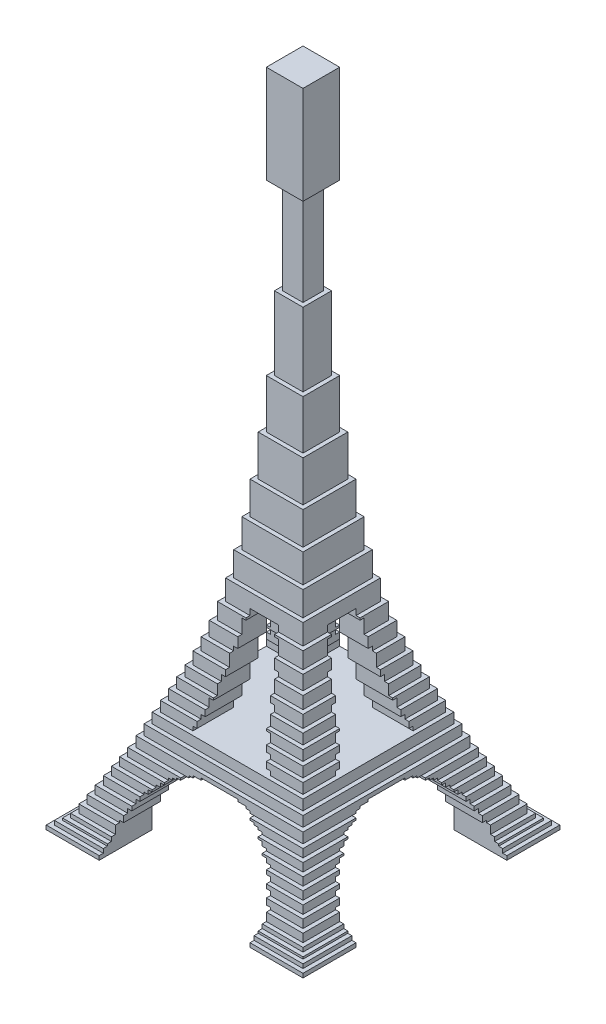
from build123d import *

# Parameters (mm, degrees)
SKIZZE2_W                            = 63
SKIZZE2_H                            = 162
AUFSATZ_LINEAR_AUSTRAGEN1_DEPTH      = 31.5
AUFSATZ_LINEAR_AUSTRAGEN1_DEPTH_BACK = 31.5
SCHNITT_LINEAR_AUSTRAGEN2_DEPTH      = 32.5
SCHNITT_LINEAR_AUSTRAGEN3_DEPTH      = 32.5
SCHNITT_LINEAR_AUSTRAGEN4_DEPTH      = 32.5
KREISMUSTER1_COUNT                   = 4
KREISMUSTER1_COPY_1_DEPTH            = 32.5
KREISMUSTER1_COPY_2_DEPTH            = 32.5
KREISMUSTER1_COPY_3_DEPTH            = 32.5
KREISMUSTER1_COPY_4_DEPTH            = 32.5
KREISMUSTER1_COPY_5_DEPTH            = 32.5
KREISMUSTER1_COPY_6_DEPTH            = 32.5
KREISMUSTER1_COPY_7_DEPTH            = 32.5
KREISMUSTER1_COPY_8_DEPTH            = 32.5
KREISMUSTER1_COPY_9_DEPTH            = 32.5
KREISMUSTER1_COPY_10_DEPTH           = 32.5
KREISMUSTER1_COPY_11_DEPTH           = 32.5
KREISMUSTER1_COPY_12_DEPTH           = 32.5


with BuildPart() as part:
    # Skizze2 → Aufsatz-Linear austragen1 (new body, two sides)
    with BuildSketch(Plane.XY) as aufsatz_linear_austragen1_sk:
        with Locations((0, 81)):
            Rectangle(SKIZZE2_W, SKIZZE2_H)
    extrude(amount=AUFSATZ_LINEAR_AUSTRAGEN1_DEPTH)
    extrude(aufsatz_linear_austragen1_sk.sketch, amount=-AUFSATZ_LINEAR_AUSTRAGEN1_DEPTH_BACK)

    # Skizze4 → Schnitt-Linear austragen2 (cut, symmetric)
    with BuildSketch(Plane.XY):
        Polygon((-18.5, 0), (-18.5, 6), (-17.5, 6), (-17.5, 8.5), (-16.5, 8.5), (-16.5, 10.5), (-15.5, 10.5), (-15.5, 12), (-14.5, 12), (-14.5, 13), (-13.5, 13), (-13.5, 14), (-12.5, 14), (-12.5, 15), (-11.5, 15), (-11.5, 16), (-10.5, 16), (-10.5, 16.5), (-9.5, 16.5), (-9.5, 17), (-8.5, 17), (-8.5, 17.5), (-7.5, 17.5), (-7.5, 18), (-6.5, 18), (-6.5, 18.5), (-4.5, 18.5), (-4.5, 19), (0, 19), (0, 0), align=None)
    schnitt_linear_austragen2 = extrude(amount=SCHNITT_LINEAR_AUSTRAGEN2_DEPTH, both=True, mode=Mode.SUBTRACT)

    # Skizze5 → Schnitt-Linear austragen3 (cut, symmetric)
    with BuildSketch(Plane.XY):
        Polygon((0, 50), (-3.5, 50), (-3.5, 48), (-4.5, 48), (-4.5, 42), (-5.5, 42), (-5.5, 36.5), (-6.5, 36.5), (-6.5, 32), (-7.5, 32), (-7.5, 28.5), (-8.5, 28.5), (-8.5, 26), (-9.5, 26), (-9.5, 25), (0, 25), align=None)
    schnitt_linear_austragen3 = extrude(amount=SCHNITT_LINEAR_AUSTRAGEN3_DEPTH, both=True, mode=Mode.SUBTRACT)

    # Skizze6 → Schnitt-Linear austragen4 (cut, symmetric)
    with BuildSketch(Plane.XY):
        Polygon((-4.5, 162), (-4.5, 138), (-2.5, 138), (-2.5, 114.5), (-3.5, 114.5), (-3.5, 96.5), (-4.5, 96.5), (-4.5, 84.5), (-5.5, 84.5), (-5.5, 74.5), (-6.5, 74.5), (-6.5, 66.5), (-7.5, 66.5), (-7.5, 59.5), (-8.5, 59.5), (-8.5, 53.5), (-9.5, 53.5), (-9.5, 48.5), (-10.5, 48.5), (-10.5, 44.5), (-11.5, 44.5), (-11.5, 41), (-12.5, 41), (-12.5, 38), (-13.5, 38), (-13.5, 35), (-14.5, 35), (-14.5, 32.5), (-15.5, 32.5), (-15.5, 30), (-16.5, 30), (-16.5, 27.5), (-17.5, 27.5), (-17.5, 25), (-18.5, 25), (-18.5, 22.5), (-19.5, 22.5), (-19.5, 20), (-20.5, 20), (-20.5, 17.5), (-21.5, 17.5), (-21.5, 15.5), (-22.5, 15.5), (-22.5, 13.5), (-23.5, 13.5), (-23.5, 11.5), (-24.5, 11.5), (-24.5, 9.5), (-25.5, 9.5), (-25.5, 7.5), (-26.5, 7.5), (-26.5, 5.5), (-27.5, 5.5), (-27.5, 3.5), (-28.5, 3.5), (-28.5, 2.5), (-29.5, 2.5), (-29.5, 2), (-30.5, 2), (-30.5, 1), (-31.5, 1), (-31.5, 162), align=None)
    schnitt_linear_austragen4 = extrude(amount=SCHNITT_LINEAR_AUSTRAGEN4_DEPTH, both=True, mode=Mode.SUBTRACT)

    # Spiegeln1: Schnitt-Linear austragen2, Schnitt-Linear austragen3, Schnitt-Linear austragen4 across plane
    add(schnitt_linear_austragen2.mirror(Plane(origin=(0, 0, 0), x_dir=(0, 0, 1), z_dir=(1, 0, 0))), mode=Mode.SUBTRACT)
    add(schnitt_linear_austragen3.mirror(Plane(origin=(0, 0, 0), x_dir=(0, 0, 1), z_dir=(1, 0, 0))), mode=Mode.SUBTRACT)
    add(schnitt_linear_austragen4.mirror(Plane(origin=(0, 0, 0), x_dir=(0, 0, 1), z_dir=(1, 0, 0))), mode=Mode.SUBTRACT)

    # Kreismuster1: Schnitt-Linear austragen2, Schnitt-Linear austragen3 ×4 about axis
    kreismuster1_axis = Axis((0, 0, 0), (0, 1, 0))
    for i in range(1, KREISMUSTER1_COUNT):
        add(schnitt_linear_austragen2.rotate(kreismuster1_axis, i * 360 / KREISMUSTER1_COUNT), mode=Mode.SUBTRACT)
        add(schnitt_linear_austragen3.rotate(kreismuster1_axis, i * 360 / KREISMUSTER1_COUNT), mode=Mode.SUBTRACT)

    # Kreismuster1 copy 1 sketch → Kreismuster1 copy 1 (cut, symmetric)
    with BuildSketch(Plane(origin=(0, 0, 0), x_dir=(0, 0, 1), z_dir=(1, 0, 0))):
        Polygon((-18.5, 0), (-18.5, -6), (-17.5, -6), (-17.5, -8.5), (-16.5, -8.5), (-16.5, -10.5), (-15.5, -10.5), (-15.5, -12), (-14.5, -12), (-14.5, -13), (-13.5, -13), (-13.5, -14), (-12.5, -14), (-12.5, -15), (-11.5, -15), (-11.5, -16), (-10.5, -16), (-10.5, -16.5), (-9.5, -16.5), (-9.5, -17), (-8.5, -17), (-8.5, -17.5), (-7.5, -17.5), (-7.5, -18), (-6.5, -18), (-6.5, -18.5), (-4.5, -18.5), (-4.5, -19), (0, -19), (0, 0), align=None)
    extrude(amount=KREISMUSTER1_COPY_1_DEPTH, both=True, mode=Mode.SUBTRACT)

    # Kreismuster1 copy 2 sketch → Kreismuster1 copy 2 (cut, symmetric)
    with BuildSketch(Plane(origin=(0, 0, 0), x_dir=(1, 0, 0), z_dir=(0, 0, -1))):
        Polygon((-18.5, 0), (-18.5, -6), (-17.5, -6), (-17.5, -8.5), (-16.5, -8.5), (-16.5, -10.5), (-15.5, -10.5), (-15.5, -12), (-14.5, -12), (-14.5, -13), (-13.5, -13), (-13.5, -14), (-12.5, -14), (-12.5, -15), (-11.5, -15), (-11.5, -16), (-10.5, -16), (-10.5, -16.5), (-9.5, -16.5), (-9.5, -17), (-8.5, -17), (-8.5, -17.5), (-7.5, -17.5), (-7.5, -18), (-6.5, -18), (-6.5, -18.5), (-4.5, -18.5), (-4.5, -19), (0, -19), (0, 0), align=None)
    extrude(amount=KREISMUSTER1_COPY_2_DEPTH, both=True, mode=Mode.SUBTRACT)

    # Kreismuster1 copy 3 sketch → Kreismuster1 copy 3 (cut, symmetric)
    with BuildSketch(Plane(origin=(0, 0, 0), x_dir=(0, 0, -1), z_dir=(-1, 0, 0))):
        Polygon((-18.5, 0), (-18.5, -6), (-17.5, -6), (-17.5, -8.5), (-16.5, -8.5), (-16.5, -10.5), (-15.5, -10.5), (-15.5, -12), (-14.5, -12), (-14.5, -13), (-13.5, -13), (-13.5, -14), (-12.5, -14), (-12.5, -15), (-11.5, -15), (-11.5, -16), (-10.5, -16), (-10.5, -16.5), (-9.5, -16.5), (-9.5, -17), (-8.5, -17), (-8.5, -17.5), (-7.5, -17.5), (-7.5, -18), (-6.5, -18), (-6.5, -18.5), (-4.5, -18.5), (-4.5, -19), (0, -19), (0, 0), align=None)
    extrude(amount=KREISMUSTER1_COPY_3_DEPTH, both=True, mode=Mode.SUBTRACT)

    # Kreismuster1 copy 4 sketch → Kreismuster1 copy 4 (cut, symmetric)
    with BuildSketch(Plane(origin=(0, 0, 0), x_dir=(0, 0, 1), z_dir=(1, 0, 0))):
        Polygon((0, -50), (-3.5, -50), (-3.5, -48), (-4.5, -48), (-4.5, -42), (-5.5, -42), (-5.5, -36.5), (-6.5, -36.5), (-6.5, -32), (-7.5, -32), (-7.5, -28.5), (-8.5, -28.5), (-8.5, -26), (-9.5, -26), (-9.5, -25), (0, -25), align=None)
    extrude(amount=KREISMUSTER1_COPY_4_DEPTH, both=True, mode=Mode.SUBTRACT)

    # Kreismuster1 copy 5 sketch → Kreismuster1 copy 5 (cut, symmetric)
    with BuildSketch(Plane(origin=(0, 0, 0), x_dir=(1, 0, 0), z_dir=(0, 0, -1))):
        Polygon((0, -50), (-3.5, -50), (-3.5, -48), (-4.5, -48), (-4.5, -42), (-5.5, -42), (-5.5, -36.5), (-6.5, -36.5), (-6.5, -32), (-7.5, -32), (-7.5, -28.5), (-8.5, -28.5), (-8.5, -26), (-9.5, -26), (-9.5, -25), (0, -25), align=None)
    extrude(amount=KREISMUSTER1_COPY_5_DEPTH, both=True, mode=Mode.SUBTRACT)

    # Kreismuster1 copy 6 sketch → Kreismuster1 copy 6 (cut, symmetric)
    with BuildSketch(Plane(origin=(0, 0, 0), x_dir=(0, 0, -1), z_dir=(-1, 0, 0))):
        Polygon((0, -50), (-3.5, -50), (-3.5, -48), (-4.5, -48), (-4.5, -42), (-5.5, -42), (-5.5, -36.5), (-6.5, -36.5), (-6.5, -32), (-7.5, -32), (-7.5, -28.5), (-8.5, -28.5), (-8.5, -26), (-9.5, -26), (-9.5, -25), (0, -25), align=None)
    extrude(amount=KREISMUSTER1_COPY_6_DEPTH, both=True, mode=Mode.SUBTRACT)

    # Kreismuster1 copy 7 sketch → Kreismuster1 copy 7 (cut, symmetric)
    with BuildSketch(Plane(origin=(0, 0, 0), x_dir=(0, 0, 1), z_dir=(1, 0, 0))):
        Polygon((-4.5, -162), (-4.5, -138), (-2.5, -138), (-2.5, -114.5), (-3.5, -114.5), (-3.5, -96.5), (-4.5, -96.5), (-4.5, -84.5), (-5.5, -84.5), (-5.5, -74.5), (-6.5, -74.5), (-6.5, -66.5), (-7.5, -66.5), (-7.5, -59.5), (-8.5, -59.5), (-8.5, -53.5), (-9.5, -53.5), (-9.5, -48.5), (-10.5, -48.5), (-10.5, -44.5), (-11.5, -44.5), (-11.5, -41), (-12.5, -41), (-12.5, -38), (-13.5, -38), (-13.5, -35), (-14.5, -35), (-14.5, -32.5), (-15.5, -32.5), (-15.5, -30), (-16.5, -30), (-16.5, -27.5), (-17.5, -27.5), (-17.5, -25), (-18.5, -25), (-18.5, -22.5), (-19.5, -22.5), (-19.5, -20), (-20.5, -20), (-20.5, -17.5), (-21.5, -17.5), (-21.5, -15.5), (-22.5, -15.5), (-22.5, -13.5), (-23.5, -13.5), (-23.5, -11.5), (-24.5, -11.5), (-24.5, -9.5), (-25.5, -9.5), (-25.5, -7.5), (-26.5, -7.5), (-26.5, -5.5), (-27.5, -5.5), (-27.5, -3.5), (-28.5, -3.5), (-28.5, -2.5), (-29.5, -2.5), (-29.5, -2), (-30.5, -2), (-30.5, -1), (-31.5, -1), (-31.5, -162), align=None)
    extrude(amount=KREISMUSTER1_COPY_7_DEPTH, both=True, mode=Mode.SUBTRACT)

    # Kreismuster1 copy 8 sketch → Kreismuster1 copy 8 (cut, symmetric)
    with BuildSketch(Plane(origin=(0, 0, 0), x_dir=(1, 0, 0), z_dir=(0, 0, -1))):
        Polygon((-4.5, -162), (-4.5, -138), (-2.5, -138), (-2.5, -114.5), (-3.5, -114.5), (-3.5, -96.5), (-4.5, -96.5), (-4.5, -84.5), (-5.5, -84.5), (-5.5, -74.5), (-6.5, -74.5), (-6.5, -66.5), (-7.5, -66.5), (-7.5, -59.5), (-8.5, -59.5), (-8.5, -53.5), (-9.5, -53.5), (-9.5, -48.5), (-10.5, -48.5), (-10.5, -44.5), (-11.5, -44.5), (-11.5, -41), (-12.5, -41), (-12.5, -38), (-13.5, -38), (-13.5, -35), (-14.5, -35), (-14.5, -32.5), (-15.5, -32.5), (-15.5, -30), (-16.5, -30), (-16.5, -27.5), (-17.5, -27.5), (-17.5, -25), (-18.5, -25), (-18.5, -22.5), (-19.5, -22.5), (-19.5, -20), (-20.5, -20), (-20.5, -17.5), (-21.5, -17.5), (-21.5, -15.5), (-22.5, -15.5), (-22.5, -13.5), (-23.5, -13.5), (-23.5, -11.5), (-24.5, -11.5), (-24.5, -9.5), (-25.5, -9.5), (-25.5, -7.5), (-26.5, -7.5), (-26.5, -5.5), (-27.5, -5.5), (-27.5, -3.5), (-28.5, -3.5), (-28.5, -2.5), (-29.5, -2.5), (-29.5, -2), (-30.5, -2), (-30.5, -1), (-31.5, -1), (-31.5, -162), align=None)
    extrude(amount=KREISMUSTER1_COPY_8_DEPTH, both=True, mode=Mode.SUBTRACT)

    # Kreismuster1 copy 9 sketch → Kreismuster1 copy 9 (cut, symmetric)
    with BuildSketch(Plane(origin=(0, 0, 0), x_dir=(0, 0, -1), z_dir=(-1, 0, 0))):
        Polygon((-4.5, -162), (-4.5, -138), (-2.5, -138), (-2.5, -114.5), (-3.5, -114.5), (-3.5, -96.5), (-4.5, -96.5), (-4.5, -84.5), (-5.5, -84.5), (-5.5, -74.5), (-6.5, -74.5), (-6.5, -66.5), (-7.5, -66.5), (-7.5, -59.5), (-8.5, -59.5), (-8.5, -53.5), (-9.5, -53.5), (-9.5, -48.5), (-10.5, -48.5), (-10.5, -44.5), (-11.5, -44.5), (-11.5, -41), (-12.5, -41), (-12.5, -38), (-13.5, -38), (-13.5, -35), (-14.5, -35), (-14.5, -32.5), (-15.5, -32.5), (-15.5, -30), (-16.5, -30), (-16.5, -27.5), (-17.5, -27.5), (-17.5, -25), (-18.5, -25), (-18.5, -22.5), (-19.5, -22.5), (-19.5, -20), (-20.5, -20), (-20.5, -17.5), (-21.5, -17.5), (-21.5, -15.5), (-22.5, -15.5), (-22.5, -13.5), (-23.5, -13.5), (-23.5, -11.5), (-24.5, -11.5), (-24.5, -9.5), (-25.5, -9.5), (-25.5, -7.5), (-26.5, -7.5), (-26.5, -5.5), (-27.5, -5.5), (-27.5, -3.5), (-28.5, -3.5), (-28.5, -2.5), (-29.5, -2.5), (-29.5, -2), (-30.5, -2), (-30.5, -1), (-31.5, -1), (-31.5, -162), align=None)
    extrude(amount=KREISMUSTER1_COPY_9_DEPTH, both=True, mode=Mode.SUBTRACT)

    # Kreismuster1 copy 10 sketch → Kreismuster1 copy 10 (cut, symmetric)
    with BuildSketch(Plane(origin=(0, 0, 0), x_dir=(0, 0, -1), z_dir=(1, 0, 0))):
        Polygon((-4.5, 162), (-4.5, 138), (-2.5, 138), (-2.5, 114.5), (-3.5, 114.5), (-3.5, 96.5), (-4.5, 96.5), (-4.5, 84.5), (-5.5, 84.5), (-5.5, 74.5), (-6.5, 74.5), (-6.5, 66.5), (-7.5, 66.5), (-7.5, 59.5), (-8.5, 59.5), (-8.5, 53.5), (-9.5, 53.5), (-9.5, 48.5), (-10.5, 48.5), (-10.5, 44.5), (-11.5, 44.5), (-11.5, 41), (-12.5, 41), (-12.5, 38), (-13.5, 38), (-13.5, 35), (-14.5, 35), (-14.5, 32.5), (-15.5, 32.5), (-15.5, 30), (-16.5, 30), (-16.5, 27.5), (-17.5, 27.5), (-17.5, 25), (-18.5, 25), (-18.5, 22.5), (-19.5, 22.5), (-19.5, 20), (-20.5, 20), (-20.5, 17.5), (-21.5, 17.5), (-21.5, 15.5), (-22.5, 15.5), (-22.5, 13.5), (-23.5, 13.5), (-23.5, 11.5), (-24.5, 11.5), (-24.5, 9.5), (-25.5, 9.5), (-25.5, 7.5), (-26.5, 7.5), (-26.5, 5.5), (-27.5, 5.5), (-27.5, 3.5), (-28.5, 3.5), (-28.5, 2.5), (-29.5, 2.5), (-29.5, 2), (-30.5, 2), (-30.5, 1), (-31.5, 1), (-31.5, 162), align=None)
    extrude(amount=KREISMUSTER1_COPY_10_DEPTH, both=True, mode=Mode.SUBTRACT)

    # Kreismuster1 copy 11 sketch → Kreismuster1 copy 11 (cut, symmetric)
    with BuildSketch(Plane(origin=(0, 0, 0), x_dir=(-1, 0, 0), z_dir=(0, 0, -1))):
        Polygon((-4.5, 162), (-4.5, 138), (-2.5, 138), (-2.5, 114.5), (-3.5, 114.5), (-3.5, 96.5), (-4.5, 96.5), (-4.5, 84.5), (-5.5, 84.5), (-5.5, 74.5), (-6.5, 74.5), (-6.5, 66.5), (-7.5, 66.5), (-7.5, 59.5), (-8.5, 59.5), (-8.5, 53.5), (-9.5, 53.5), (-9.5, 48.5), (-10.5, 48.5), (-10.5, 44.5), (-11.5, 44.5), (-11.5, 41), (-12.5, 41), (-12.5, 38), (-13.5, 38), (-13.5, 35), (-14.5, 35), (-14.5, 32.5), (-15.5, 32.5), (-15.5, 30), (-16.5, 30), (-16.5, 27.5), (-17.5, 27.5), (-17.5, 25), (-18.5, 25), (-18.5, 22.5), (-19.5, 22.5), (-19.5, 20), (-20.5, 20), (-20.5, 17.5), (-21.5, 17.5), (-21.5, 15.5), (-22.5, 15.5), (-22.5, 13.5), (-23.5, 13.5), (-23.5, 11.5), (-24.5, 11.5), (-24.5, 9.5), (-25.5, 9.5), (-25.5, 7.5), (-26.5, 7.5), (-26.5, 5.5), (-27.5, 5.5), (-27.5, 3.5), (-28.5, 3.5), (-28.5, 2.5), (-29.5, 2.5), (-29.5, 2), (-30.5, 2), (-30.5, 1), (-31.5, 1), (-31.5, 162), align=None)
    extrude(amount=KREISMUSTER1_COPY_11_DEPTH, both=True, mode=Mode.SUBTRACT)

    # Kreismuster1 copy 12 sketch → Kreismuster1 copy 12 (cut, symmetric)
    with BuildSketch(Plane.ZY):
        Polygon((-4.5, 162), (-4.5, 138), (-2.5, 138), (-2.5, 114.5), (-3.5, 114.5), (-3.5, 96.5), (-4.5, 96.5), (-4.5, 84.5), (-5.5, 84.5), (-5.5, 74.5), (-6.5, 74.5), (-6.5, 66.5), (-7.5, 66.5), (-7.5, 59.5), (-8.5, 59.5), (-8.5, 53.5), (-9.5, 53.5), (-9.5, 48.5), (-10.5, 48.5), (-10.5, 44.5), (-11.5, 44.5), (-11.5, 41), (-12.5, 41), (-12.5, 38), (-13.5, 38), (-13.5, 35), (-14.5, 35), (-14.5, 32.5), (-15.5, 32.5), (-15.5, 30), (-16.5, 30), (-16.5, 27.5), (-17.5, 27.5), (-17.5, 25), (-18.5, 25), (-18.5, 22.5), (-19.5, 22.5), (-19.5, 20), (-20.5, 20), (-20.5, 17.5), (-21.5, 17.5), (-21.5, 15.5), (-22.5, 15.5), (-22.5, 13.5), (-23.5, 13.5), (-23.5, 11.5), (-24.5, 11.5), (-24.5, 9.5), (-25.5, 9.5), (-25.5, 7.5), (-26.5, 7.5), (-26.5, 5.5), (-27.5, 5.5), (-27.5, 3.5), (-28.5, 3.5), (-28.5, 2.5), (-29.5, 2.5), (-29.5, 2), (-30.5, 2), (-30.5, 1), (-31.5, 1), (-31.5, 162), align=None)
    extrude(amount=KREISMUSTER1_COPY_12_DEPTH, both=True, mode=Mode.SUBTRACT)


solid = part.part
